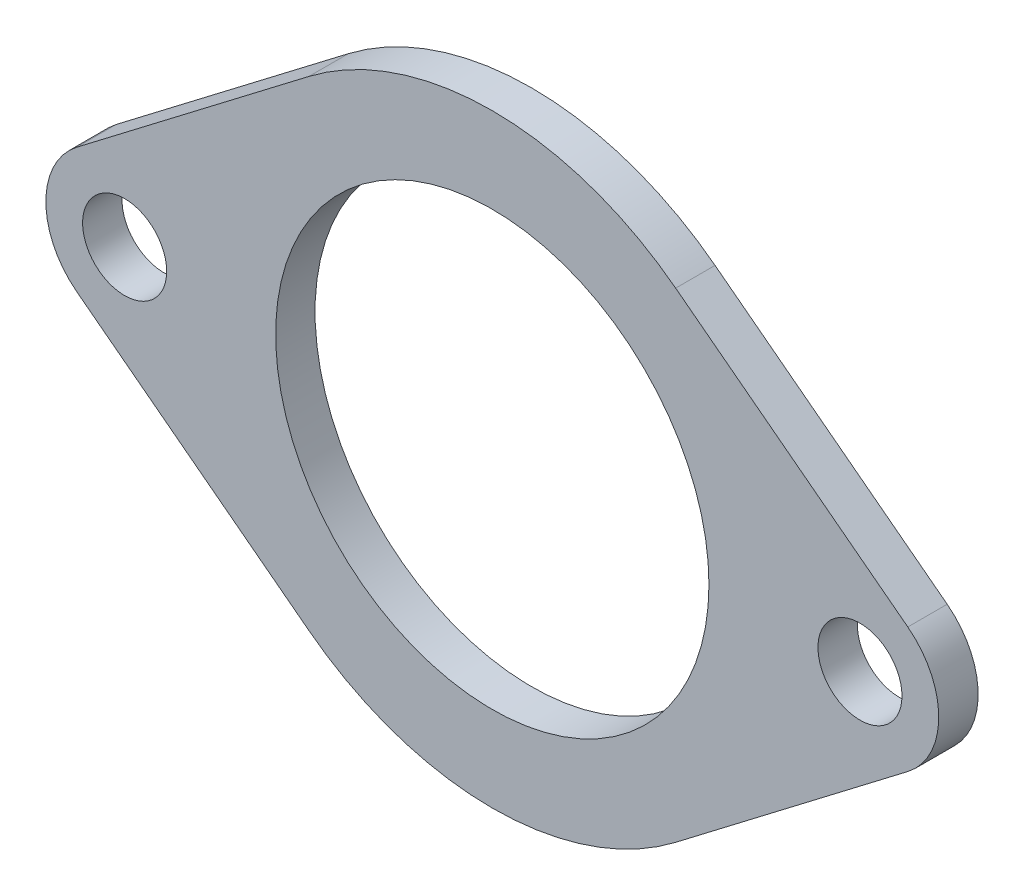
from build123d import *

# Parameters (mm, degrees)
SKETCH_1_R      = 8.25
SKETCH_1_R_2    = 1.6
EXTRUDE_1_DEPTH = 1.5


with BuildPart() as part:
    # ｽｹｯﾁ1 → ﾎﾞｽ - 押し出し1 (new body)
    with BuildSketch(Plane.XY):
        with BuildLine():
            Line((-15.821428571, 2.383778085), (-6.982142857, 9.137815993))
            ThreePointArc((-6.982142857, 9.137815993), (0, 11.5), (6.982142857, 9.137815993))
            Line((6.982142857, 9.137815993), (15.821428571, 2.383778085))
            ThreePointArc((15.821428571, 2.383778085), (17, 0), (15.821428571, -2.383778085))
            Line((15.821428571, -2.383778085), (6.982142857, -9.137815993))
            ThreePointArc((6.982142857, -9.137815993), (0, -11.5), (-6.982142857, -9.137815993))
            Line((-6.982142857, -9.137815993), (-15.821428571, -2.383778085))
            ThreePointArc((-15.821428571, -2.383778085), (-17, 0), (-15.821428571, 2.383778085))
        make_face()
        Circle(SKETCH_1_R, mode=Mode.SUBTRACT)
        with Locations((-14, 0)):
            Circle(SKETCH_1_R_2, mode=Mode.SUBTRACT)
        with Locations((14, 0)):
            Circle(SKETCH_1_R_2, mode=Mode.SUBTRACT)
    extrude(amount=EXTRUDE_1_DEPTH)


solid = part.part
